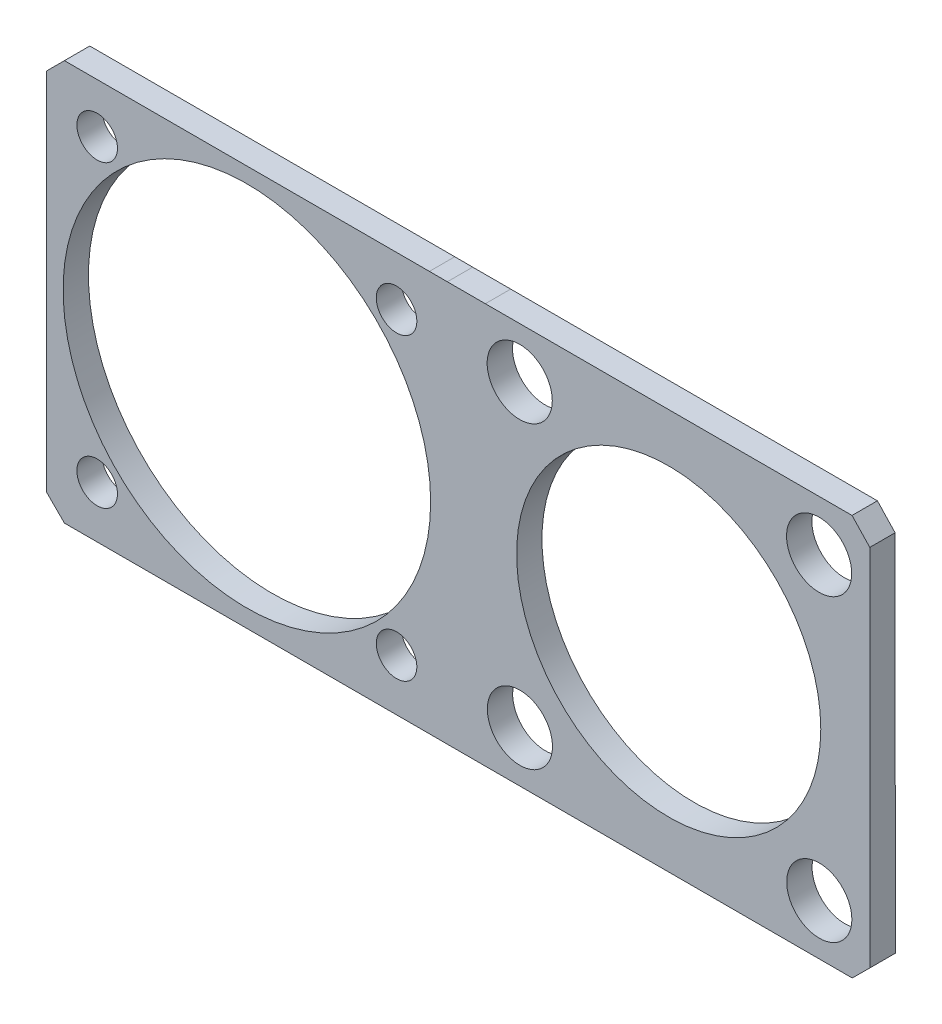
from build123d import *

# Parameters (mm, degrees)
MODEL_R             = 2.032
MODEL_R_2           = 3.2639
MODEL_R_3           = 15.24
MODEL_R_4           = 18.415
BOSS_EXTRUDE1_DEPTH = 2.54


with BuildPart() as part:
    # Model → Boss-Extrude1 (new body)
    with BuildSketch(Plane.XY):
        Polygon((23.89577784, 19.950554749), (20.085777841, 19.950499596), (18.29294446, 19.955499209), (-18.28305554, 19.955499209), (-20.06105554, 18.177499209), (-20.06105554, -18.398500791), (-18.28305554, -20.176500791), (18.29294446, -20.176500791), (20.066, -20.181445251), (23.876, -20.181445251), (60.660238165, -20.181445251), (62.438238165, -18.413722656), (62.418460324, 18.066456797), (60.640460324, 19.950554749), align=None)
        with Locations((-14.99997, -14.99997)):
            Circle(MODEL_R, mode=Mode.SUBTRACT)
        with Locations((14.99997, -14.99997)):
            Circle(MODEL_R, mode=Mode.SUBTRACT)
        with Locations((27.358298165, -15.115415251)):
            Circle(MODEL_R_2, mode=Mode.SUBTRACT)
        with Locations((57.358238165, -15.115415251)):
            Circle(MODEL_R_2, mode=Mode.SUBTRACT)
        with Locations((42.268119082, -0.17363293)):
            Circle(MODEL_R_3, mode=Mode.SUBTRACT)
        Circle(MODEL_R_4, mode=Mode.SUBTRACT)
        with Locations((-14.99997, 14.99997)):
            Circle(MODEL_R, mode=Mode.SUBTRACT)
        with Locations((14.99997, 14.99997)):
            Circle(MODEL_R, mode=Mode.SUBTRACT)
        with Locations((27.340244675, 14.884524749)):
            Circle(MODEL_R_2, mode=Mode.SUBTRACT)
        with Locations((57.340184675, 14.884519317)):
            Circle(MODEL_R_2, mode=Mode.SUBTRACT)
    extrude(amount=-BOSS_EXTRUDE1_DEPTH)


solid = part.part
